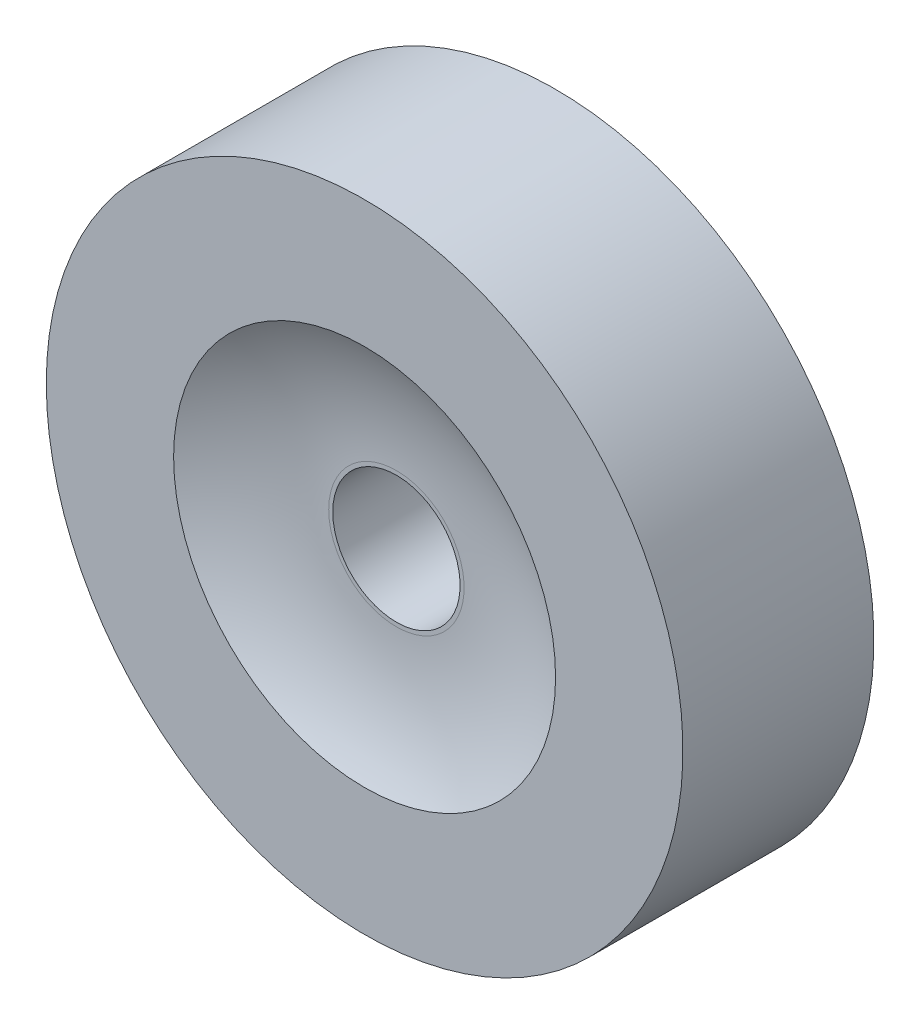
from build123d import *


with BuildPart() as part:
    # Sketch1 → Revolve1 (revolve)
    with BuildSketch(Plane.XZ.offset(7.80542761)):
        with BuildLine():
            Line((7.58439152, 0.2), (7.58439152, 0.5))
            Line((7.58439152, 0.5), (7.38439152, 0.5))
            ThreePointArc((7.38439152, 0.5), (7.290742353, 0.462701665), (7.190742353, 0.45))
            Line((7.190742353, 0.45), (7.18439152, 0.45))
            Line((7.18439152, 0.45), (7.18439152, 0.2))
            Line((7.18439152, 0.2), (7.58439152, 0.2))
        make_face()
    revolve(axis=Axis((7.08439152, -7.80542761, 0.5), (0, 0, -1)))


solid = part.part
